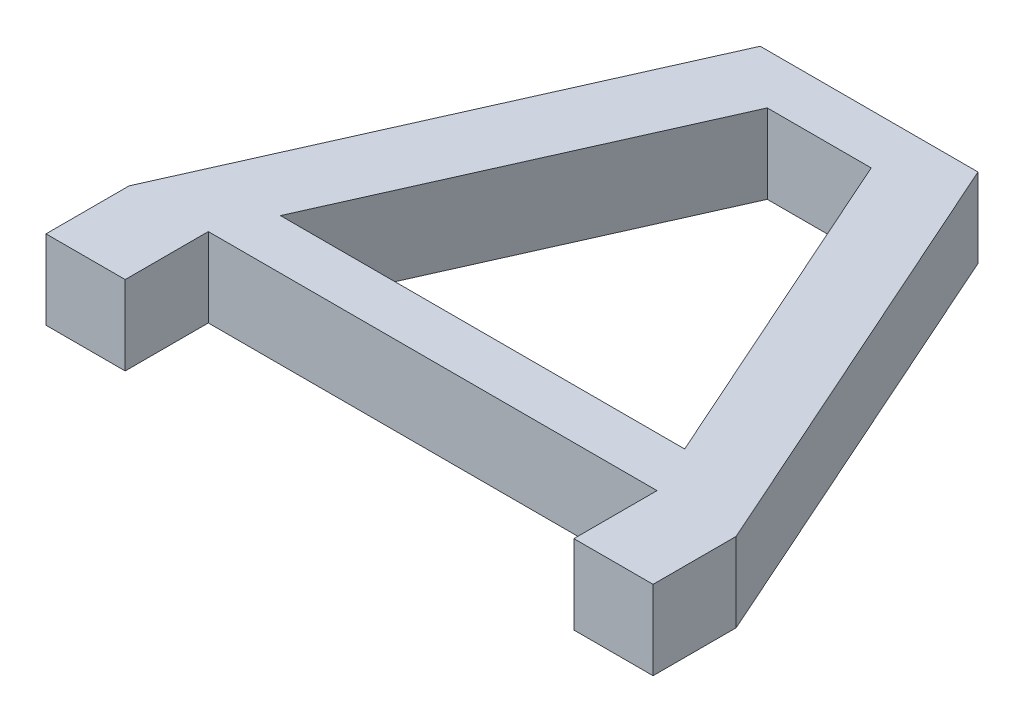
from build123d import *

# Parameters (mm, degrees)
BOSS_EXTRUDE1_DEPTH = 19.05


with BuildPart() as part:
    # Sketch1 → Boss-Extrude1 (new body)
    with BuildSketch(Plane(origin=(0, 0, 0), x_dir=(1, 0, 0), z_dir=(0, 1, 0))):
        Polygon((-73.025, -10), (-53.975, -10), (-53.975, 10), (53.975, 10), (53.975, -10), (73.025, -10), (73.025, 10), (26.198387097, 115), (-26.198387097, 115), (-73.025, 10), align=None)
        Polygon((-12.5, 103), (12.5, 103), (48.623387097, 22), (-48.623387097, 22), align=None, mode=Mode.SUBTRACT)
    extrude(amount=BOSS_EXTRUDE1_DEPTH)


solid = part.part
